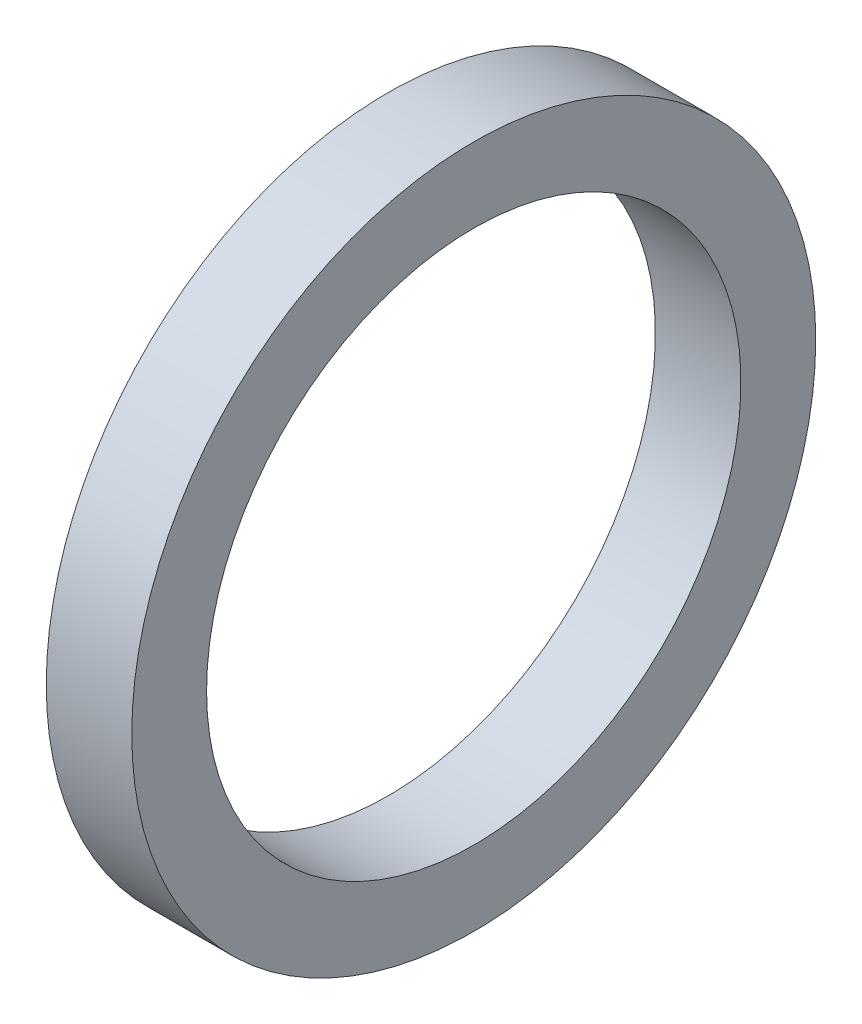
from build123d import *

# Parameters (mm, degrees)
SKETCH1_W = 4
SKETCH1_H = 3.5


with BuildPart() as part:
    # Sketch1 → Revolve1 (revolve)
    with BuildSketch(Plane.XY):
        with Locations((0, 14.25)):
            Rectangle(SKETCH1_W, SKETCH1_H)
    revolve(axis=Axis((0, 0, 0), (1, 0, 0)))


solid = part.part
